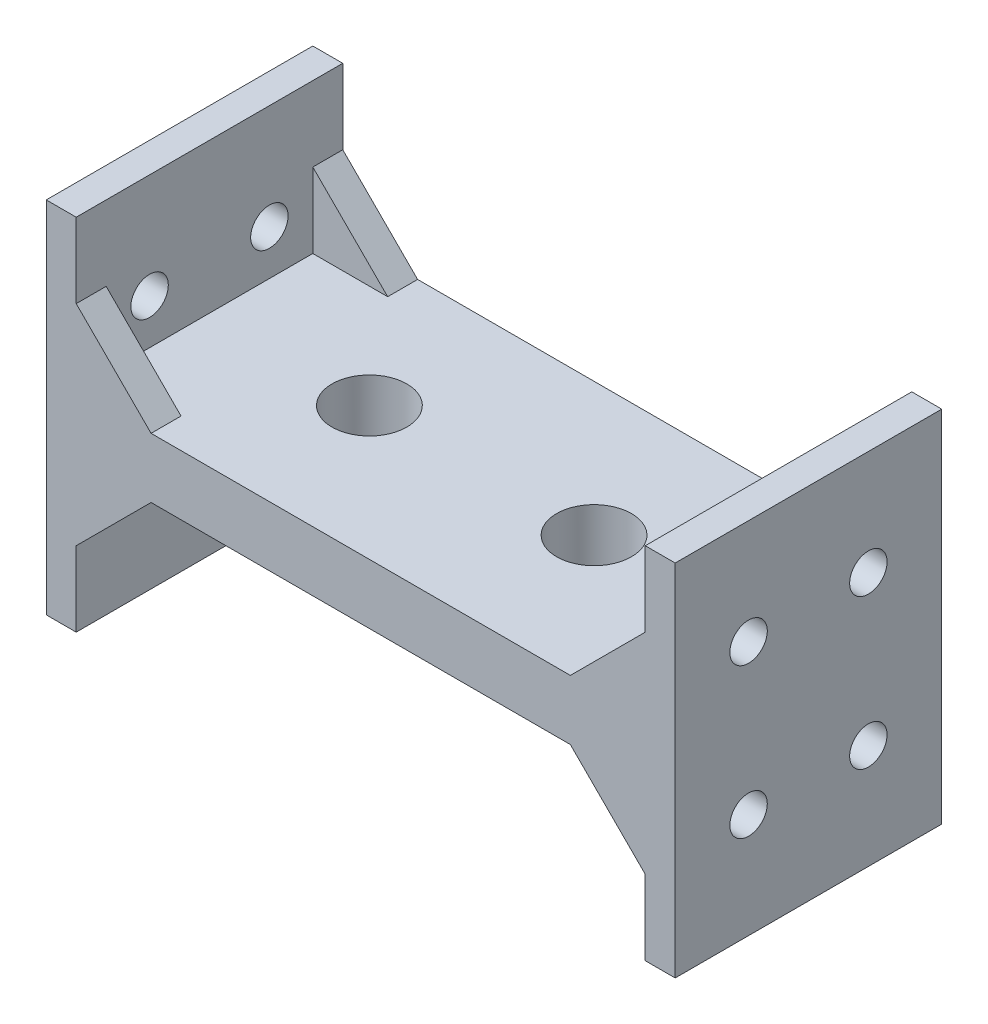
from build123d import *

# Parameters (mm, degrees)
SKETCH2_W               = 42
SKETCH2_H               = 17.8
BOSS_EXTRUDE1_DEPTH     = 4
SKETCH3_W               = 2
SKETCH3_H               = 17.8
BOSS_EXTRUDE2_DEPTH     = 10
BOSS_EXTRUDE3_DEPTH     = 2
SKETCH5_R               = 2.5
CUT_EXTRUDE1_DEPTH      = 11
CUT_EXTRUDE1_DEPTH_BACK = 5
SKETCH6_R               = 1.25
CUT_EXTRUDE2_DEPTH      = 2
SKETCH7_W               = 2
SKETCH7_H               = 17.8
BOSS_EXTRUDE4_DEPTH     = 10
SKETCH8_R               = 1.25
CUT_EXTRUDE3_DEPTH      = 10
BOSS_EXTRUDE5_DEPTH     = 2


with BuildPart() as part:
    # Sketch2 → Boss-Extrude1 (new body)
    with BuildSketch(Plane(origin=(0, 0, 0), x_dir=(1, 0, 0), z_dir=(0, 1, 0))):
        Rectangle(SKETCH2_W, SKETCH2_H)
    extrude(amount=BOSS_EXTRUDE1_DEPTH)

    # Sketch3 → Boss-Extrude2 (add)
    with BuildSketch(Plane.XZ):
        with Locations((-20, 0)):
            Rectangle(SKETCH3_W, SKETCH3_H)
        with Locations((20, 0)):
            Rectangle(SKETCH3_W, SKETCH3_H)
    extrude(amount=BOSS_EXTRUDE2_DEPTH)

    # Sketch4 → Boss-Extrude3 (add)
    with BuildSketch(Plane.XY.offset(8.9)):
        Polygon((-19, 0), (-14, 0), (-19, -5), align=None)
        Polygon((19, -5), (14, 0), (19, 0), align=None)
    boss_extrude3 = extrude(amount=-BOSS_EXTRUDE3_DEPTH)

    # Mirror1: Boss-Extrude3 across plane
    add(boss_extrude3.mirror(Plane.XY))

    # Sketch5 → Cut-Extrude1 (cut, two sides)
    with BuildSketch(Plane.XZ) as cut_extrude1_sk:
        with Locations((-8.319906625, 0)):
            Circle(SKETCH5_R)
        with Locations((6.680093375, 0)):
            Circle(SKETCH5_R)
    extrude(amount=CUT_EXTRUDE1_DEPTH, mode=Mode.SUBTRACT)
    extrude(cut_extrude1_sk.sketch, amount=-CUT_EXTRUDE1_DEPTH_BACK, mode=Mode.SUBTRACT)

    # Sketch6 → Cut-Extrude2 (cut)
    with BuildSketch(Plane(origin=(-19, 0, 0), x_dir=(0, 0, -1), z_dir=(1, 0, 0))):
        with Locations((-4, -3)):
            Circle(SKETCH6_R)
        with Locations((4, -3)):
            Circle(SKETCH6_R)
    cut_extrude2 = extrude(amount=-CUT_EXTRUDE2_DEPTH, mode=Mode.SUBTRACT)

    # Mirror2: Cut-Extrude2 across plane
    add(cut_extrude2.mirror(Plane(origin=(0, 0, 0), x_dir=(0, 0, 1), z_dir=(1, 0, 0))), mode=Mode.SUBTRACT)

    # Sketch7 → Boss-Extrude4 (add)
    with BuildSketch(Plane(origin=(0, 4, 0), x_dir=(1, 0, 0), z_dir=(0, 1, 0))):
        with Locations((-20, 0)):
            Rectangle(SKETCH7_W, SKETCH7_H)
        with Locations((20, 0)):
            Rectangle(SKETCH7_W, SKETCH7_H)
    extrude(amount=BOSS_EXTRUDE4_DEPTH)

    # Sketch8 → Cut-Extrude3 (cut)
    with BuildSketch(Plane(origin=(-19, 0, 0), x_dir=(0, 0, -1), z_dir=(1, 0, 0))):
        with Locations((-4, 7)):
            Circle(SKETCH8_R)
        with Locations((4, 7)):
            Circle(SKETCH8_R)
    cut_extrude3 = extrude(amount=-CUT_EXTRUDE3_DEPTH, mode=Mode.SUBTRACT)

    # Mirror3: Cut-Extrude3 across plane
    add(cut_extrude3.mirror(Plane(origin=(0, 0, 0), x_dir=(0, 0, 1), z_dir=(1, 0, 0))), mode=Mode.SUBTRACT)

    # Sketch9 → Boss-Extrude5 (add)
    with BuildSketch(Plane(origin=(0, 0, -8.9), x_dir=(-1, 0, 0), z_dir=(0, 0, -1))):
        Polygon((-19, 9), (-19, 4), (-14, 4), align=None)
        Polygon((19, 9), (14, 4), (19, 4), align=None)
    boss_extrude5 = extrude(amount=-BOSS_EXTRUDE5_DEPTH)

    # Mirror4: Boss-Extrude5 across plane
    add(boss_extrude5.mirror(Plane.XY))


solid = part.part
